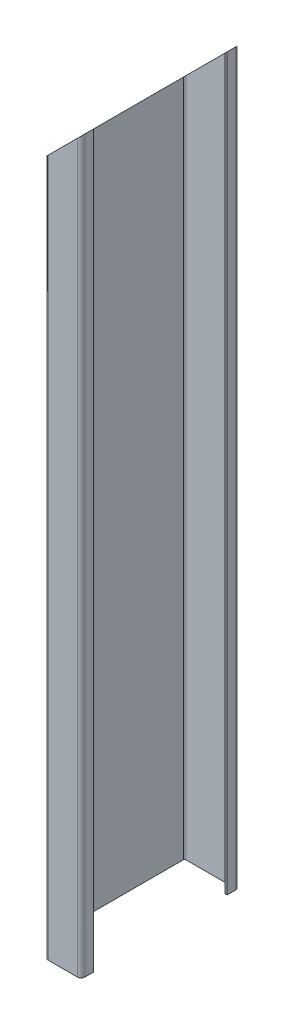
from build123d import *

# Parameters (mm, degrees)
VYSUNOUT_TENKOST_NN_1_DEPTH = 600
ODEBRAT_VYSUNUT_M1_DEPTH    = 130


with BuildPart() as part:
    # Skica1 → Vysunout tenkostěnný1 (new body)
    with BuildSketch(Plane(origin=(0, 0, 0), x_dir=(1, 0, 0), z_dir=(0, 1, 0))):
        with BuildLine():
            Line((22.5, -55), (22.5, -62))
            ThreePointArc((22.5, -62), (21.621320344, -64.121320344), (19.5, -65))
            Line((19.5, -65), (-4.5, -65))
            ThreePointArc((-4.5, -65), (-6.621320344, -64.121320344), (-7.5, -62))
            Line((-7.5, -62), (-7.5, -31))
            ThreePointArc((-7.5, -31), (-7.792893219, -30.292893219), (-8.5, -30))
            Line((-8.5, -30), (-19.5, -30))
            ThreePointArc((-19.5, -30), (-21.621320344, -29.121320344), (-22.5, -27))
            Line((-22.5, -27), (-22.5, 62))
            ThreePointArc((-22.5, 62), (-21.621320344, 64.121320344), (-19.5, 65))
            Line((-19.5, 65), (19.5, 65))
            ThreePointArc((19.5, 65), (21.621320344, 64.121320344), (22.5, 62))
            Line((22.5, 62), (22.5, 55))
            Line((22.5, 55), (20.5, 55))
            Line((20.5, 55), (20.5, 62))
            ThreePointArc((20.5, 62), (20.207106781, 62.707106781), (19.5, 63))
            Line((19.5, 63), (-19.5, 63))
            ThreePointArc((-19.5, 63), (-20.207106781, 62.707106781), (-20.5, 62))
            Line((-20.5, 62), (-20.5, -27))
            ThreePointArc((-20.5, -27), (-20.207106781, -27.707106781), (-19.5, -28))
            Line((-19.5, -28), (-8.5, -28))
            ThreePointArc((-8.5, -28), (-6.378679656, -28.878679656), (-5.5, -31))
            Line((-5.5, -31), (-5.5, -62))
            ThreePointArc((-5.5, -62), (-5.207106781, -62.707106781), (-4.5, -63))
            Line((-4.5, -63), (19.5, -63))
            ThreePointArc((19.5, -63), (20.207106781, -62.707106781), (20.5, -62))
            Line((20.5, -62), (20.5, -55))
            Line((20.5, -55), (22.5, -55))
        make_face()
    extrude(amount=VYSUNOUT_TENKOST_NN_1_DEPTH)

    # Skica2 → Odebrat vysunutím1 (cut)
    with BuildSketch(Plane.XY.offset(65)):
        Polygon((22.5, 600), (-22.5, 600), (-22.5, 555), align=None)
    extrude(amount=-ODEBRAT_VYSUNUT_M1_DEPTH, mode=Mode.SUBTRACT)


solid = part.part
